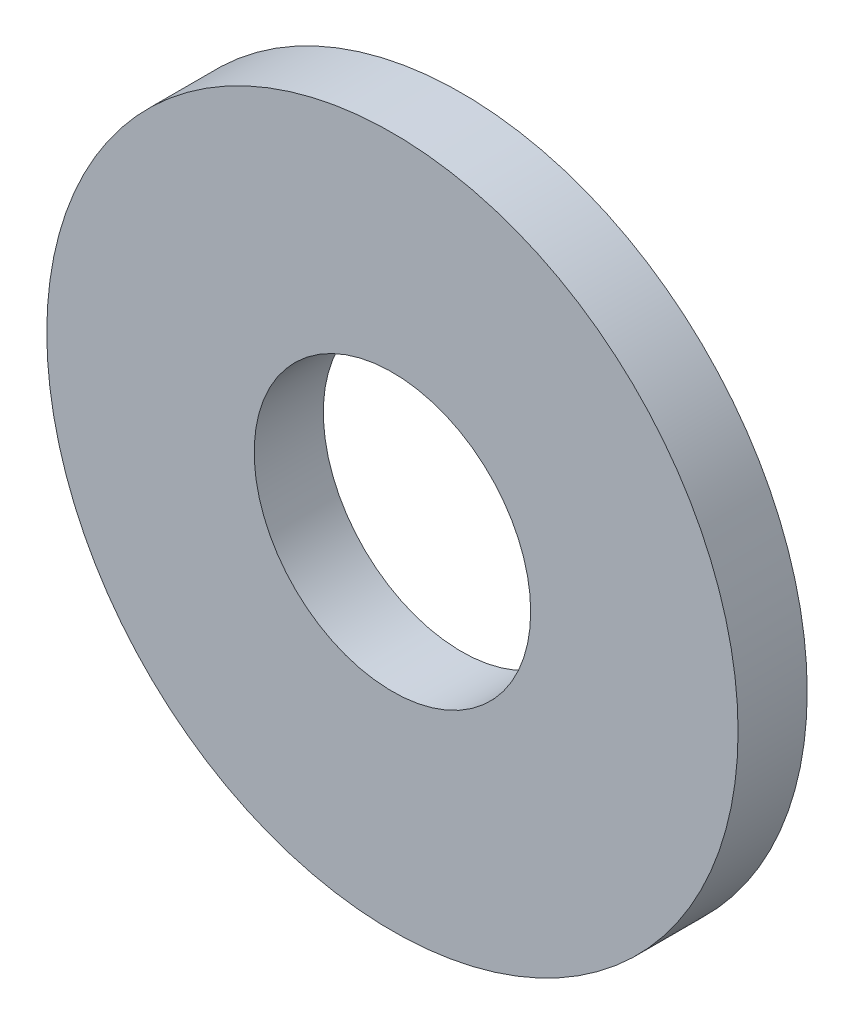
from build123d import *

# Parameters (mm, degrees)
SKETCH1_R           = 5
SKETCH1_R_2         = 2
BOSS_EXTRUDE1_DEPTH = 1


with BuildPart() as part:
    # Sketch1 → Boss-Extrude1 (new body)
    with BuildSketch(Plane.XY):
        Circle(SKETCH1_R)
        Circle(SKETCH1_R_2, mode=Mode.SUBTRACT)
    extrude(amount=BOSS_EXTRUDE1_DEPTH)


solid = part.part
